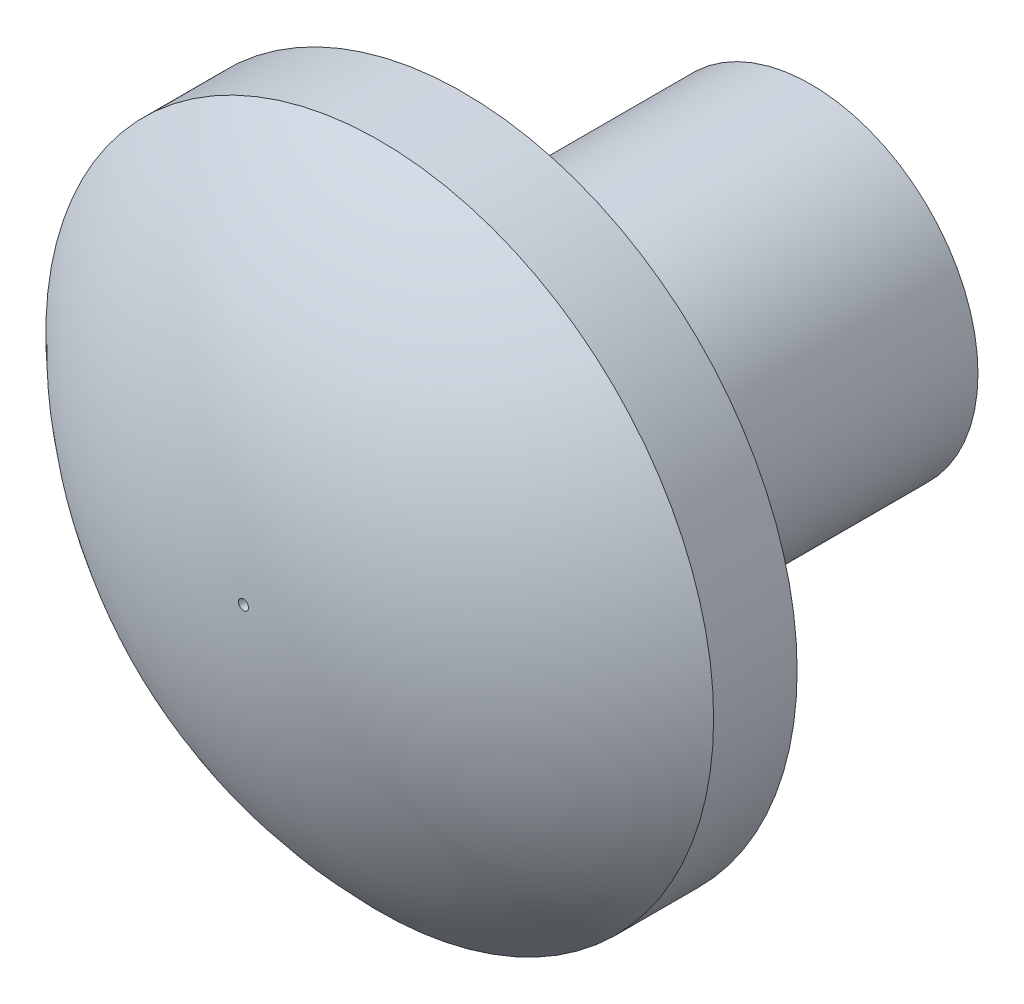
from build123d import *

# Parameters (mm, degrees)
SKETCH1_R           = 3
BOSS_EXTRUDE1_DEPTH = 6.25
SKETCH2_R           = 6
BOSS_EXTRUDE2_DEPTH = 1.5


with BuildPart() as part:
    # Sketch1 → Boss-Extrude1 (new body)
    with BuildSketch(Plane.XY):
        Circle(SKETCH1_R)
    extrude(amount=BOSS_EXTRUDE1_DEPTH)

    # Sketch2 → Boss-Extrude2 (add)
    with BuildSketch(Plane.XY.offset(6.25)):
        Circle(SKETCH2_R)
    extrude(amount=BOSS_EXTRUDE2_DEPTH)

    # Sketch3 → Revolve1 (revolve)
    with BuildSketch(Plane(origin=(0, 0, 0), x_dir=(0, 0, -1), z_dir=(1, 0, 0))):
        with BuildLine():
            Line((-7.75, 6), (-7.75, 0.09036269))
            Line((-7.75, 0.09036269), (-10.197851923, 0.09036269))
            ThreePointArc((-10.197851923, 0.09036269), (-9.561675935, 3.288635355), (-7.75, 6))
        make_face()
    revolve(axis=Axis((0, 0, 6.25), (0, 0, -1)))


solid = part.part
